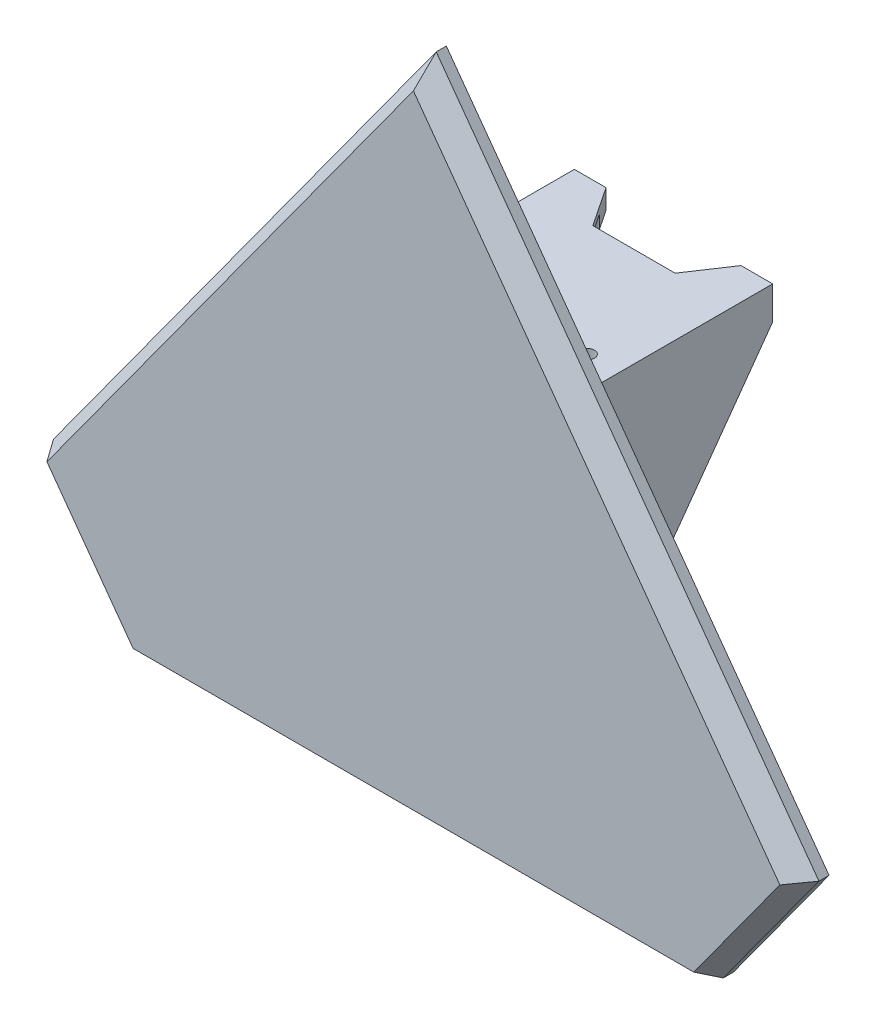
from build123d import *

# Parameters (mm, degrees)
BOSS_EXTRUDE1_DEPTH     = 32.5
SKETCH4_R               = 1.05
BOSS_EXTRUDE2_DEPTH     = 2.5
SKETCH5_R               = 1.05
BOSS_EXTRUDE3_DEPTH     = 3
CUT_EXTRUDE1_DEPTH      = 31.122
SKETCH13_W              = 30.122
SKETCH13_H              = 38
BOSS_EXTRUDE7_DEPTH     = 2.5
BOSS_EXTRUDE4_DEPTH     = 5
BOSS_EXTRUDE6_DEPTH     = 5
CUT_EXTRUDE2_DEPTH      = 6
SKETCH12_W              = 16.4999
SKETCH12_H              = 2
CUT_EXTRUDE4_DEPTH      = 10
CUT_EXTRUDE4_DEPTH_BACK = 23.5
CHAMFER1_SIZE           = 2
CHAMFER1_SIZE2          = 3.464101615


with BuildPart() as part:
    # Sketch2 → Boss-Extrude1 (new body)
    with BuildSketch(Plane(origin=(0, 0, 0), x_dir=(1, 0, 0), z_dir=(0, 1, 0))):
        Polygon((15.061, 0), (15.061, 32), (12.561, 32), (12.561, 2.5), (-12.561, 2.5), (-12.561, 32), (-15.061, 32), (-15.061, 0), align=None)
    extrude(amount=BOSS_EXTRUDE1_DEPTH)

    # Sketch4 → Boss-Extrude2 (add)
    with BuildSketch(Plane.XZ):
        Polygon((-7.5, -6), (7.5, -6), (12.561, -10), (15.061, -10), (15.061, 0), (-15.061, 0), (-15.061, -10), (-12.561, -10), align=None)
        with Locations((-10.2499, -4.95)):
            Circle(SKETCH4_R, mode=Mode.SUBTRACT)
        with Locations((10.2499, -4.95)):
            Circle(SKETCH4_R, mode=Mode.SUBTRACT)
    extrude(amount=BOSS_EXTRUDE2_DEPTH)

    # Sketch5 → Boss-Extrude3 (add)
    with BuildSketch(Plane(origin=(0, 32.5, 0), x_dir=(1, 0, 0), z_dir=(0, 1, 0))):
        Polygon((-15.061, 32), (-10.2499, 32), (-6.25, 26), (6.25, 26), (10.2499, 32), (15.061, 32), (15.061, 0), (-15.061, 0), align=None)
        with Locations((-10.2499, 8.7)):
            Circle(SKETCH5_R, mode=Mode.SUBTRACT)
        with Locations((10.2499, 8.7)):
            Circle(SKETCH5_R, mode=Mode.SUBTRACT)
    extrude(amount=BOSS_EXTRUDE3_DEPTH)

    # Sketch6 → Cut-Extrude1 (cut, through all)
    with BuildSketch(Plane.ZY.offset(15.061)):
        Polygon((-10, 0), (-32, 30.5), (-32, 0), align=None)
    extrude(amount=-CUT_EXTRUDE1_DEPTH, mode=Mode.SUBTRACT)

    # Sketch13 → Boss-Extrude7 (add)
    with BuildSketch(Plane.XY):
        with Locations((0, 16.5)):
            Rectangle(SKETCH13_W, SKETCH13_H)
    extrude(amount=BOSS_EXTRUDE7_DEPTH)

    # Sketch8 → Boss-Extrude4 (add)
    with BuildSketch(Plane.XY.offset(2.5)):
        Polygon((0, 76.5), (43.59255168, 16.5), (-43.59255168, 16.5), align=None)
    extrude(amount=BOSS_EXTRUDE4_DEPTH)

    # Sketch9 → Boss-Extrude6 (add)
    with BuildSketch(Plane.XY.offset(2.5)):
        Polygon((-43.59255168, 16.5), (-72.654252801, -23.5), (72.654252801, -23.5), (43.59255168, 16.5), align=None)
    extrude(amount=BOSS_EXTRUDE6_DEPTH)

    # Sketch10 → Cut-Extrude2 (cut, through all)
    with BuildSketch(Plane(origin=(0, 0, 2.5), x_dir=(-1, 0, 0), z_dir=(0, 0, -1))):
        Polygon((-43.59255168, -23.5), (-58.12340224, -3.5), (-72.654252801, -23.5), align=None)
        Polygon((72.654252801, -23.5), (58.12340224, -3.5), (43.59255168, -23.5), align=None)
    extrude(amount=-CUT_EXTRUDE2_DEPTH, mode=Mode.SUBTRACT)

    # Sketch12 → Cut-Extrude4 (cut, two sides)
    with BuildSketch(Plane(origin=(0, 0, -26), x_dir=(-1, 0, 0), z_dir=(0, 0, -1))) as cut_extrude4_sk:
        with Locations((0, 33.5)):
            Rectangle(SKETCH12_W, SKETCH12_H)
    extrude(amount=CUT_EXTRUDE4_DEPTH, mode=Mode.SUBTRACT)
    extrude(cut_extrude4_sk.sketch, amount=-CUT_EXTRUDE4_DEPTH_BACK, mode=Mode.SUBTRACT)

    # Chamfer1
    chamfer1_edges = [part.edges().sort_by_distance(p)[0] for p in [
        (-29.06170112, 36.5, 7.5),
        (0, -23.5, 7.5),
        (29.06170112, 36.5, 7.5),
        (50.85797696, -13.5, 7.5),
        (-50.85797696, -13.5, 7.5),
    ]]
    chamfer1_side = [part.faces().sort_by_distance(p)[0] for p in [
        (0, 12.152173913, 7.5),
    ]]
    chamfer(chamfer1_edges, length=CHAMFER1_SIZE, length2=CHAMFER1_SIZE2, reference=chamfer1_side[0])


solid = part.part
